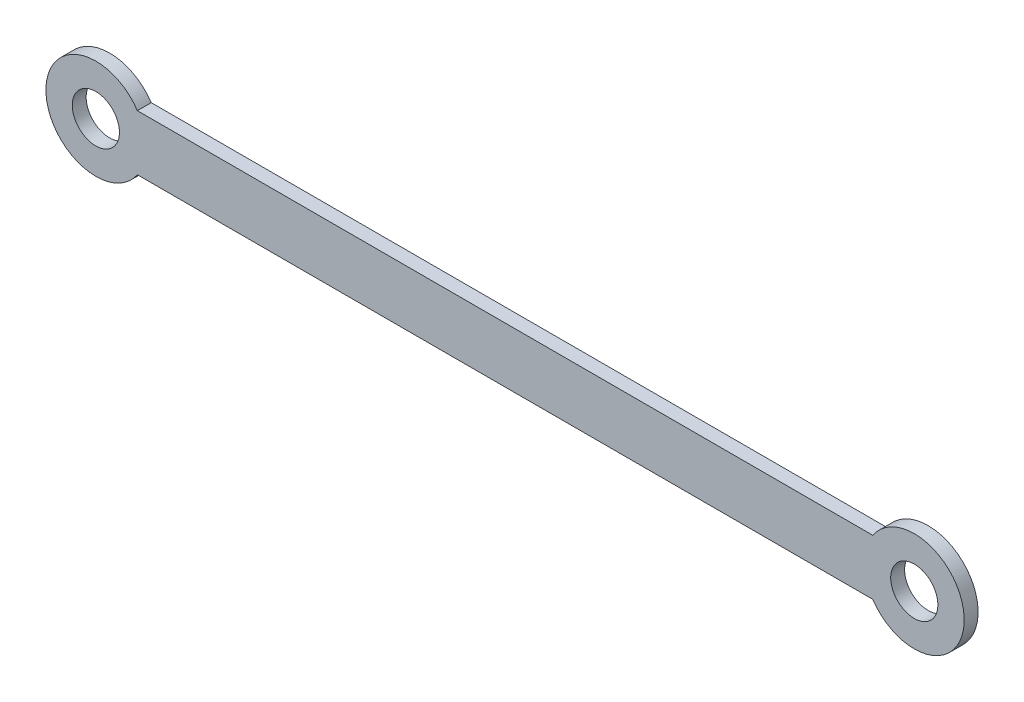
from build123d import *

# Parameters (mm, degrees)
SKETCH_1_R      = 4.25
EXTRUDE_1_DEPTH = 2.5


with BuildPart() as part:
    # 草图1 → 凸台-拉伸1 (new body)
    with BuildSketch(Plane.XY):
        with BuildLine():
            Line((7.483314774, 5), (140.016685226, 5))
            ThreePointArc((140.016685226, 5), (156.5, 0), (140.016685226, -5))
            Line((140.016685226, -5), (7.483314774, -5))
            ThreePointArc((7.483314774, -5), (-9, 0), (7.483314774, 5))
        make_face()
        Circle(SKETCH_1_R, mode=Mode.SUBTRACT)
        with Locations((147.5, 0)):
            Circle(SKETCH_1_R, mode=Mode.SUBTRACT)
    extrude(amount=EXTRUDE_1_DEPTH)


solid = part.part
